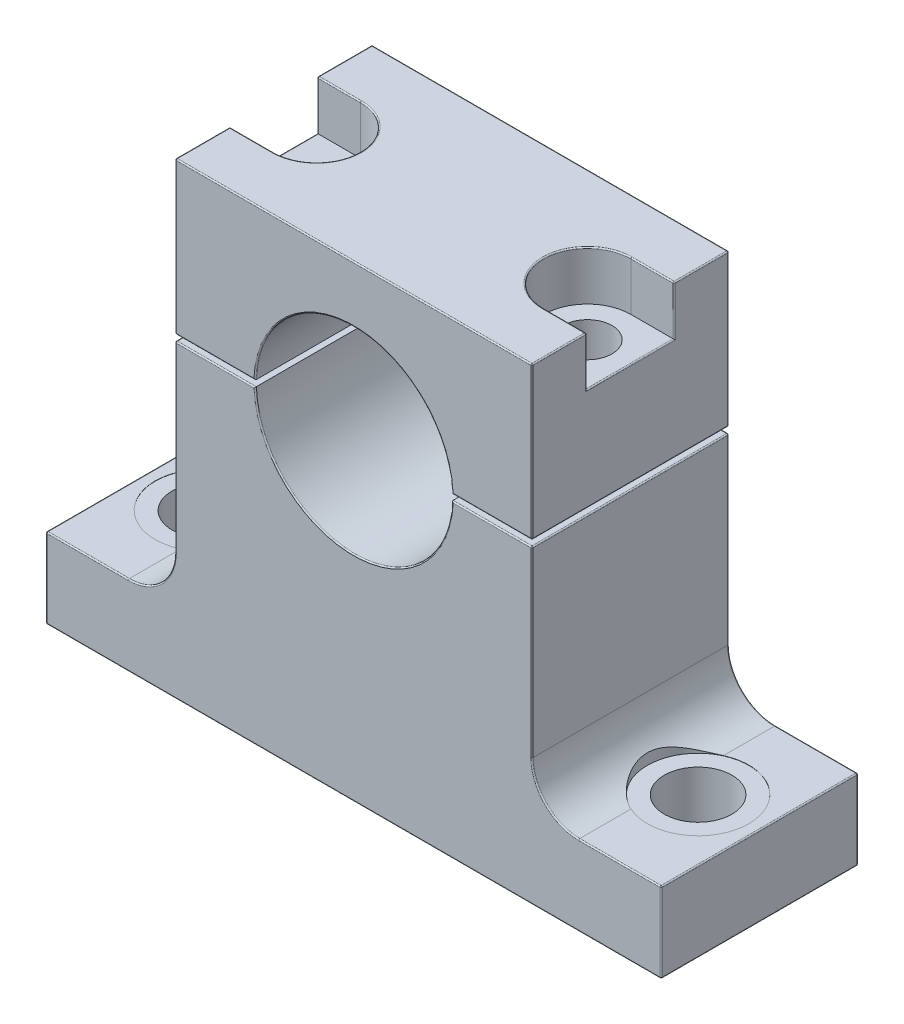
from build123d import *

# Parameters (mm, degrees)
BOSS_EXTRUDE1_DEPTH     = 8
BOSS_EXTRUDE1_2_DEPTH   = 8
SKETCH4_R               = 2.75
CUT_EXTRUDE1_DEPTH      = 42.003048667
SKETCH5_R               = 4.125
CUT_EXTRUDE2_DEPTH      = 42.003048667
CUT_EXTRUDE2_DEPTH_BACK = 0.02
SKETCH6_R               = 3.55
CUT_EXTRUDE3_DEPTH      = 4
CUT_EXTRUDE6_DEPTH      = 4
SKETCH8_R               = 2
CUT_EXTRUDE4_DEPTH      = 47.184412972
FILLET1_R               = 0.1
FILLET2_R               = 0.1


with BuildPart() as part:
    # Sketch2 → Boss-Extrude1 (new, symmetric)
    with BuildSketch(Plane.XY):
        with BuildLine():
            Line((-14.5, 12.6), (14.5, 12.6))
            Line((14.5, 12.6), (14.5, 0.25))
            Line((14.5, 0.25), (7.996092796, 0.25))
            ThreePointArc((7.996092796, 0.25), (0, 8), (-7.996092796, 0.25))
            Line((-7.996092796, 0.25), (-14.5, 0.25))
            Line((-14.5, 0.25), (-14.5, 12.6))
        make_face()
    extrude(amount=BOSS_EXTRUDE1_DEPTH, both=True)

    # Sketch6 → Cut-Extrude3 (cut)
    with BuildSketch(Plane(origin=(0, 12.6, 0), x_dir=(1, 0, 0), z_dir=(0, 1, 0))):
        with Locations((-11, 0)):
            Circle(SKETCH6_R)
        with Locations((11, 0)):
            Circle(SKETCH6_R)
    extrude(amount=-CUT_EXTRUDE3_DEPTH, mode=Mode.SUBTRACT)

    # Sketch12 → Cut-Extrude6 (cut)
    with BuildSketch(Plane(origin=(0, 12.6, 0), x_dir=(1, 0, 0), z_dir=(0, 1, 0))):
        with BuildLine():
            Line((-11, 3.55), (-14.5, 3.55))
            Line((-14.5, 3.55), (-14.5, -3.55))
            Line((-14.5, -3.55), (-11, -3.55))
            ThreePointArc((-11, -3.55), (-7.45, 0), (-11, 3.55))
        make_face()
        with BuildLine():
            Line((14.5, -3.55), (11, -3.55))
            ThreePointArc((11, -3.55), (7.45, 0), (11, 3.55))
            Line((11, 3.55), (14.5, 3.55))
            Line((14.5, 3.55), (14.5, -3.55))
        make_face()
    extrude(amount=-CUT_EXTRUDE6_DEPTH, mode=Mode.SUBTRACT)


with BuildPart() as body_2:
    # Sketch2 → Boss-Extrude1 2 (new, symmetric)
    with BuildSketch(Plane.XY):
        with BuildLine():
            Line((25, -25.4), (-25, -25.4))
            Line((-25, -25.4), (-25, -18.9))
            Line((-25, -18.9), (-18.3, -18.9))
            ThreePointArc((-18.3, -18.9), (-15.612994231, -17.787005769), (-14.5, -15.1))
            Line((-14.5, -15.1), (-14.5, -0.25))
            Line((-14.5, -0.25), (-7.996092796, -0.25))
            ThreePointArc((-7.996092796, -0.25), (0, -8), (7.996092796, -0.25))
            Line((7.996092796, -0.25), (14.5, -0.25))
            Line((14.5, -0.25), (14.5, -15.1))
            ThreePointArc((14.5, -15.1), (15.612994231, -17.787005769), (18.3, -18.9))
            Line((18.3, -18.9), (25, -18.9))
            Line((25, -18.9), (25, -25.4))
        make_face()
    extrude(amount=BOSS_EXTRUDE1_2_DEPTH, both=True)

    # Sketch4 → Cut-Extrude1 (cut, through all)
    with BuildSketch(Plane(origin=(0, -18.9, 0), x_dir=(1, 0, 0), z_dir=(0, 1, 0))):
        with Locations(Location((-20, 0, 0), (0, 0, 180))):
            Circle(SKETCH4_R)
        with Locations(Location((20, 0, 0), (0, 0, 180))):
            Circle(SKETCH4_R)
    extrude(amount=-CUT_EXTRUDE1_DEPTH, mode=Mode.SUBTRACT)

    # Sketch5 → Cut-Extrude2 (cut, two sides)
    with BuildSketch(Plane(origin=(0, -18.9, 0), x_dir=(1, 0, 0), z_dir=(0, 1, 0))) as cut_extrude2_sk:
        with Locations(Location((20, 0, 0), (0, 0, 114.33815586))):
            Circle(SKETCH5_R)
        with Locations(Location((-20, 0, 0), (0, 0, 65.66184414))):
            Circle(SKETCH5_R)
    extrude(amount=CUT_EXTRUDE2_DEPTH, mode=Mode.SUBTRACT)
    extrude(cut_extrude2_sk.sketch, amount=-CUT_EXTRUDE2_DEPTH_BACK, mode=Mode.SUBTRACT)


with BuildPart() as cut_extrude4_tool:
    # Sketch8 → Cut-Extrude4 (new, through all)
    with BuildSketch(Plane(origin=(0, 12.6, 0), x_dir=(1, 0, 0), z_dir=(0, 1, 0))):
        with Locations(Location((11, 0, 0), (0, 0, 180))):
            Circle(SKETCH8_R)
        with Locations(Location((-11, 0, 0), (0, 0, 180))):
            Circle(SKETCH8_R)
    extrude(amount=-CUT_EXTRUDE4_DEPTH)


with BuildPart() as part_1:
    add(part.part)

    # Cut-Extrude4: cut by cut_extrude4_tool
    add(cut_extrude4_tool.part, mode=Mode.SUBTRACT)

    # Fillet2
    fillet2_edges = [part_1.edges().sort_by_distance(p)[0] for p in [
        (0, 8, 8),
        (-14.5, 12.6, 5.775),
        (14.5, 12.6, 5.775),
        (14.5, 0.25, 0),
        (-14.5, 0.25, 0),
        (11.248046398, 0.25, 8),
        (14.5, 6.425, 8),
        (0, 12.6, 8),
        (14.5, 8.6, 0),
        (-14.5, 8.6, 0),
        (-7.45, 12.6, 0),
        (-14.5, 6.425, 8),
        (7.45, 12.6, 0),
        (-14.5, 12.6, -5.775),
        (14.5, 12.6, -5.775),
        (-14.5, 10.6, 3.55),
        (-12.75, 12.6, -3.55),
        (-12.75, 12.6, 3.55),
        (-14.5, 10.6, -3.55),
        (0, 12.6, -8),
        (14.5, 10.6, -3.55),
        (12.75, 12.6, -3.55),
        (12.75, 12.6, 3.55),
        (14.5, 6.425, -8),
        (14.5, 10.6, 3.55),
        (11.248046398, 0.25, -8),
        (-11.248046398, 0.25, 8),
        (0, 8, -8),
        (-11.248046398, 0.25, -8),
        (-14.5, 6.425, -8),
    ]]
    fillet(fillet2_edges, radius=FILLET2_R)


with BuildPart() as body_2_1:
    add(body_2.part)

    # Cut-Extrude4: cut by cut_extrude4_tool
    add(cut_extrude4_tool.part, mode=Mode.SUBTRACT)

    # Fillet1
    fillet1_edges = [body_2_1.edges().sort_by_distance(p)[0] for p in [
        (15.612994231, -17.787005769, 8),
        (0, -25.4, -8),
        (-25, -22.15, -8),
        (-21.65, -18.9, -8),
        (-15.612994231, -17.787005769, -8),
        (-14.5, -7.675, -8),
        (-11.248046398, -0.25, -8),
        (14.5, -7.675, 8),
        (0, -8, -8),
        (11.248046398, -0.25, -8),
        (14.5, -7.675, -8),
        (15.612994231, -17.787005769, -8),
        (21.65, -18.9, -8),
        (25, -22.15, -8),
        (11.248046398, -0.25, 8),
        (0, -8, 8),
        (25, -25.4, 0),
        (-25, -25.4, 0),
        (-25, -18.9, 0),
        (-14.5, -0.25, 0),
        (14.5, -0.25, 0),
        (25, -18.9, 0),
        (-11.248046398, -0.25, 8),
        (-14.5, -7.675, 8),
        (-15.612994231, -17.787005769, 8),
        (-21.65, -18.9, 8),
        (-25, -22.15, 8),
        (0, -25.4, 8),
        (25, -22.15, 8),
        (21.65, -18.9, 8),
    ]]
    fillet(fillet1_edges, radius=FILLET1_R)


solid = Compound([part_1.part, body_2_1.part])
